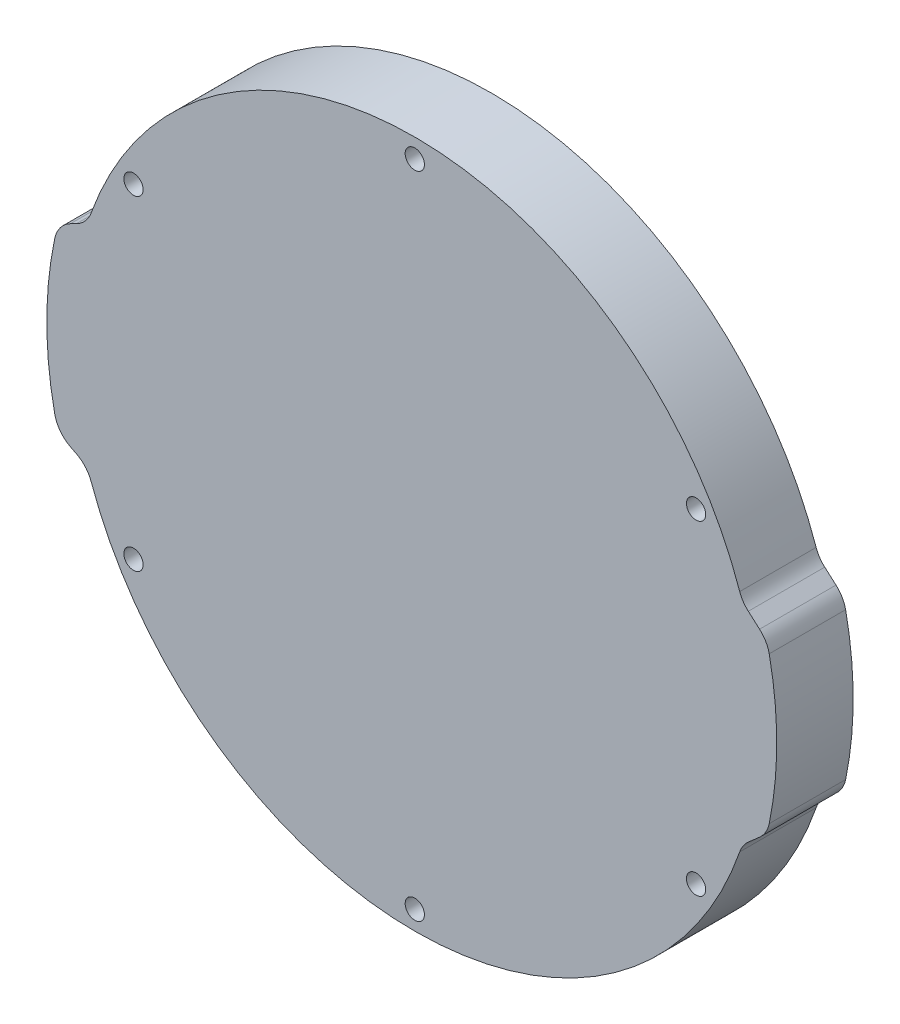
from build123d import *

# Parameters (mm, degrees)
SKETCH1_R           = 1.6
BOSS_EXTRUDE1_DEPTH = 12.7
FILLET1_R           = 5


with BuildPart() as part:
    # Sketch1 → Boss-Extrude1 (new body)
    with BuildSketch(Plane.XY):
        with BuildLine():
            Line((-59.281721466, 15), (-54.404710274, 17.5))
            ThreePointArc((-54.404710274, 17.5), (0, 57.15), (54.404710274, 17.5))
            Line((54.404710274, 17.5), (58.525108251, 13.886475587))
            ThreePointArc((58.525108251, 13.886475587), (60.15, 0), (58.525108251, -13.886475587))
            Line((58.525108251, -13.886475587), (54.404710274, -17.5))
            ThreePointArc((54.404710274, -17.5), (0, -57.15), (-54.404710274, -17.5))
            Line((-54.404710274, -17.5), (-59.281721466, -15))
            ThreePointArc((-59.281721466, -15), (-61.15, 0), (-59.281721466, 15))
        make_face()
        with Locations((0, 53.975)):
            Circle(SKETCH1_R, mode=Mode.SUBTRACT)
        with Locations((46.743721169, 26.9875)):
            Circle(SKETCH1_R, mode=Mode.SUBTRACT)
        with Locations((46.743721169, -26.9875)):
            Circle(SKETCH1_R, mode=Mode.SUBTRACT)
        with Locations((0, -53.975)):
            Circle(SKETCH1_R, mode=Mode.SUBTRACT)
        with Locations((-46.743721169, -26.9875)):
            Circle(SKETCH1_R, mode=Mode.SUBTRACT)
        with Locations((-46.743721169, 26.9875)):
            Circle(SKETCH1_R, mode=Mode.SUBTRACT)
    extrude(amount=BOSS_EXTRUDE1_DEPTH)

    # Fillet1
    fillet1_edges = [part.edges().sort_by_distance(p)[0] for p in [
        (58.525108251, -13.886475587, 6.35),
        (54.404710274, -17.5, 6.35),
        (-54.404710274, -17.5, 6.35),
        (-59.281721466, -15, 6.35),
        (-59.281721466, 15, 6.35),
        (-54.404710274, 17.5, 6.35),
        (54.404710274, 17.5, 6.35),
        (58.525108251, 13.886475587, 6.35),
    ]]
    fillet(fillet1_edges, radius=FILLET1_R)


solid = part.part
